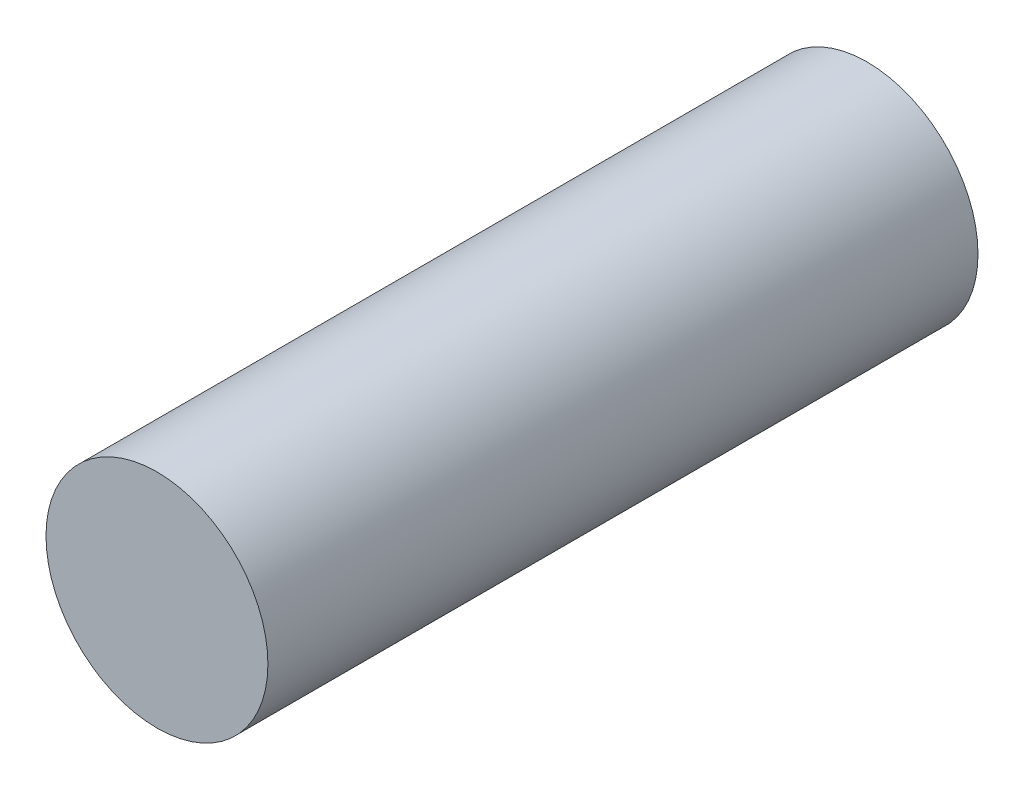
from build123d import *

# Parameters (mm, degrees)
SKETCH1_R           = 6.25
BOSS_EXTRUDE1_DEPTH = 40


with BuildPart() as part:
    # Sketch1 → Boss-Extrude1 (new body)
    with BuildSketch(Plane.XY):
        Circle(SKETCH1_R)
    extrude(amount=BOSS_EXTRUDE1_DEPTH)


solid = part.part
